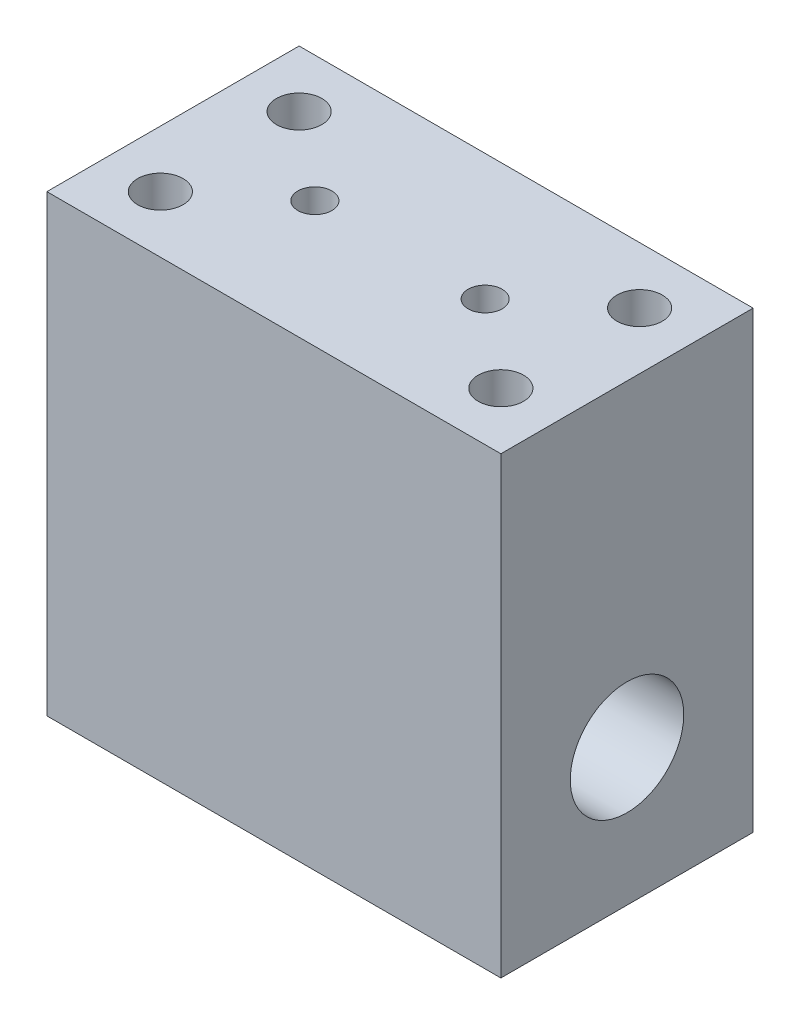
from build123d import *

# Parameters (mm, degrees)
ESBO_O2_W                = 80
ESBO_O2_H                = 80
RESSALTO_EXTRUS_O2_DEPTH = 22.225
ESBO_O10_R               = 4
ESBO_O10_R_2             = 3
CORTE_EXTRUS_O5_DEPTH    = 30
ESBO_O12_R               = 10
CORTE_EXTRUS_O7_DEPTH    = 81


with BuildPart() as part:
    # Esboço2 → Ressalto-extrusão2 (new body, symmetric)
    with BuildSketch(Plane.XY):
        Rectangle(ESBO_O2_W, ESBO_O2_H)
    extrude(amount=RESSALTO_EXTRUS_O2_DEPTH, both=True)

    # Esboço10 → Corte-extrusão5 (cut)
    with BuildSketch(Plane(origin=(0, 40, 0), x_dir=(1, 0, 0), z_dir=(0, 1, 0))):
        with Locations((30, -12.225)):
            Circle(ESBO_O10_R)
        with Locations((30, 12.225)):
            Circle(ESBO_O10_R)
        with Locations((-30, -12.225)):
            Circle(ESBO_O10_R)
        with Locations((-30, 12.225)):
            Circle(ESBO_O10_R)
        with Locations((15, 0)):
            Circle(ESBO_O10_R_2)
        with Locations((-15, 0)):
            Circle(ESBO_O10_R_2)
    extrude(amount=-CORTE_EXTRUS_O5_DEPTH, mode=Mode.SUBTRACT)

    # Esboço12 → Corte-extrusão7 (cut, through all)
    with BuildSketch(Plane(origin=(40, 0, 0), x_dir=(0, 0, -1), z_dir=(1, 0, 0))):
        with Locations((0, -15.9)):
            Circle(ESBO_O12_R)
    extrude(amount=-CORTE_EXTRUS_O7_DEPTH, mode=Mode.SUBTRACT)


solid = part.part
